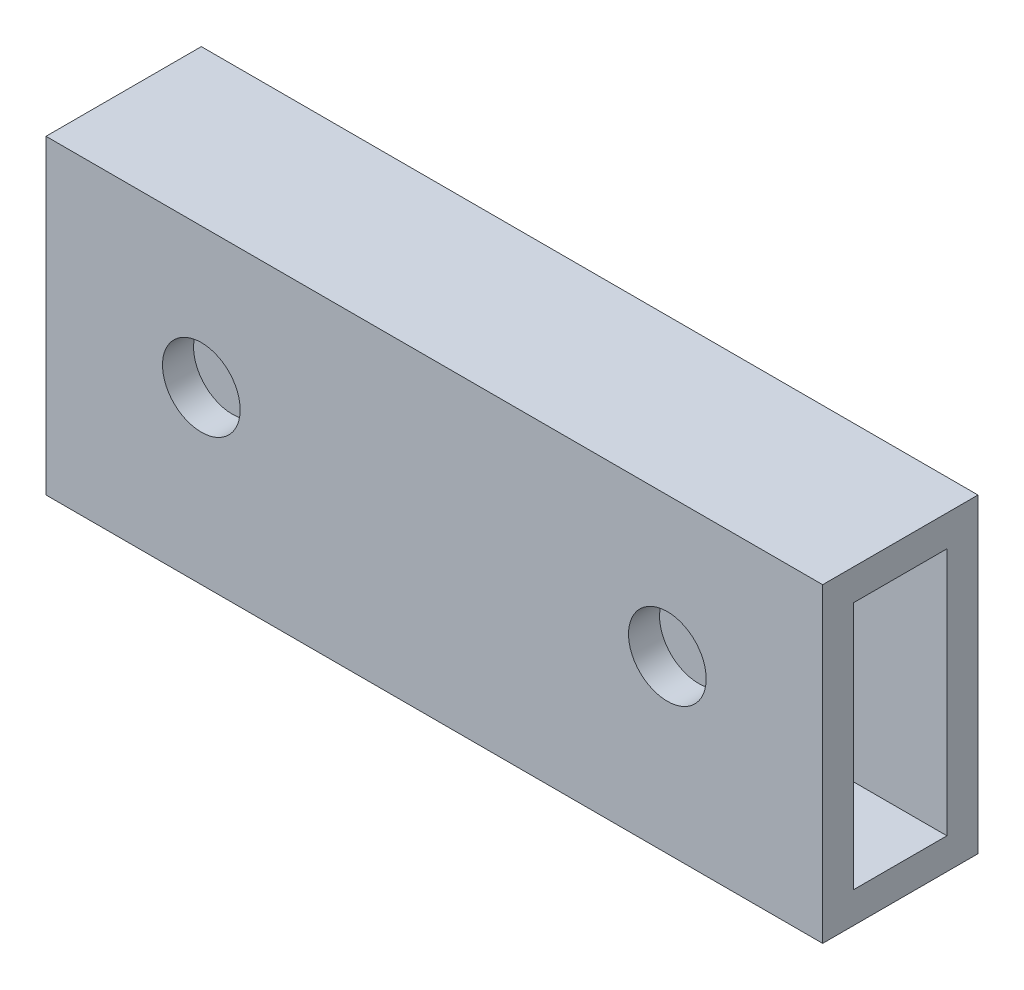
from build123d import *

# Parameters (mm, degrees)
SKETCH1_W          = 50
SKETCH1_H          = 20
EXTRUDE1_DEPTH     = 10
SKETCH2_W          = 6
SKETCH2_H          = 16
CUT_EXTRUDE1_DEPTH = 60
CUT_EXTRUDE2_DEPTH = 30


with BuildPart() as part:
    # Sketch1 → Extrude1 (new body)
    with BuildSketch(Plane.XY):
        with Locations((-71.138674094, 124.333988555)):
            Rectangle(SKETCH1_W, SKETCH1_H)
    extrude(amount=EXTRUDE1_DEPTH)

    # Sketch2 → Cut-Extrude1 (cut)
    with BuildSketch(Plane.ZY.offset(96.138674094)):
        with Locations((5, 124.333988555)):
            Rectangle(SKETCH2_W, SKETCH2_H)
    extrude(amount=-CUT_EXTRUDE1_DEPTH, mode=Mode.SUBTRACT)

    # Sketch3 → Cut-Extrude2 (cut)
    with BuildSketch(Plane.XY.offset(10)):
        with BuildLine():
            ThreePointArc((-56.138674094, 127.833988555), (-58.638674094, 125.333988555), (-56.138674094, 122.833988555))
            ThreePointArc((-56.138674094, 122.833988555), (-53.638674094, 125.333988555), (-56.138674094, 127.833988555))
        make_face()
        with BuildLine():
            ThreePointArc((-86.138674094, 127.833988555), (-88.638674094, 125.333988555), (-86.138674094, 122.833988555))
            ThreePointArc((-86.138674094, 122.833988555), (-83.638674094, 125.333988555), (-86.138674094, 127.833988555))
        make_face()
    extrude(amount=-CUT_EXTRUDE2_DEPTH, mode=Mode.SUBTRACT)


solid = part.part
